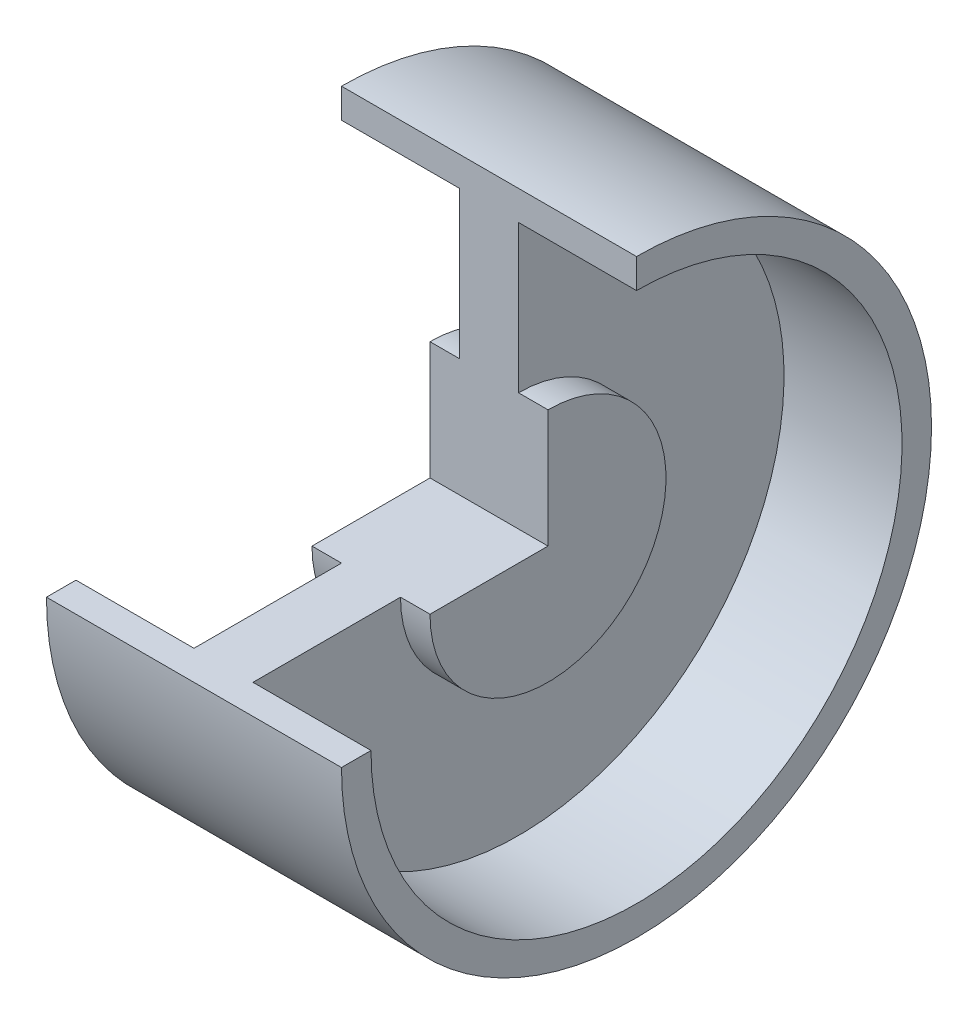
from build123d import *

# Parameters (mm, degrees)
REVOLVE2_ANGLE = 270


with BuildPart() as part:
    # Sketch1 → Revolve2 (revolve)
    with BuildSketch(Plane.XY):
        Polygon((-10, 0), (10, 0), (10, 20), (5, 20), (5, 45), (25, 45), (25, 50), (-25, 50), (-25, 45), (-5, 45), (-5, 20), (-10, 20), align=None)
    revolve(axis=Axis((-10, 0, 0), (-1, 0, 0)), revolution_arc=REVOLVE2_ANGLE)


solid = part.part
